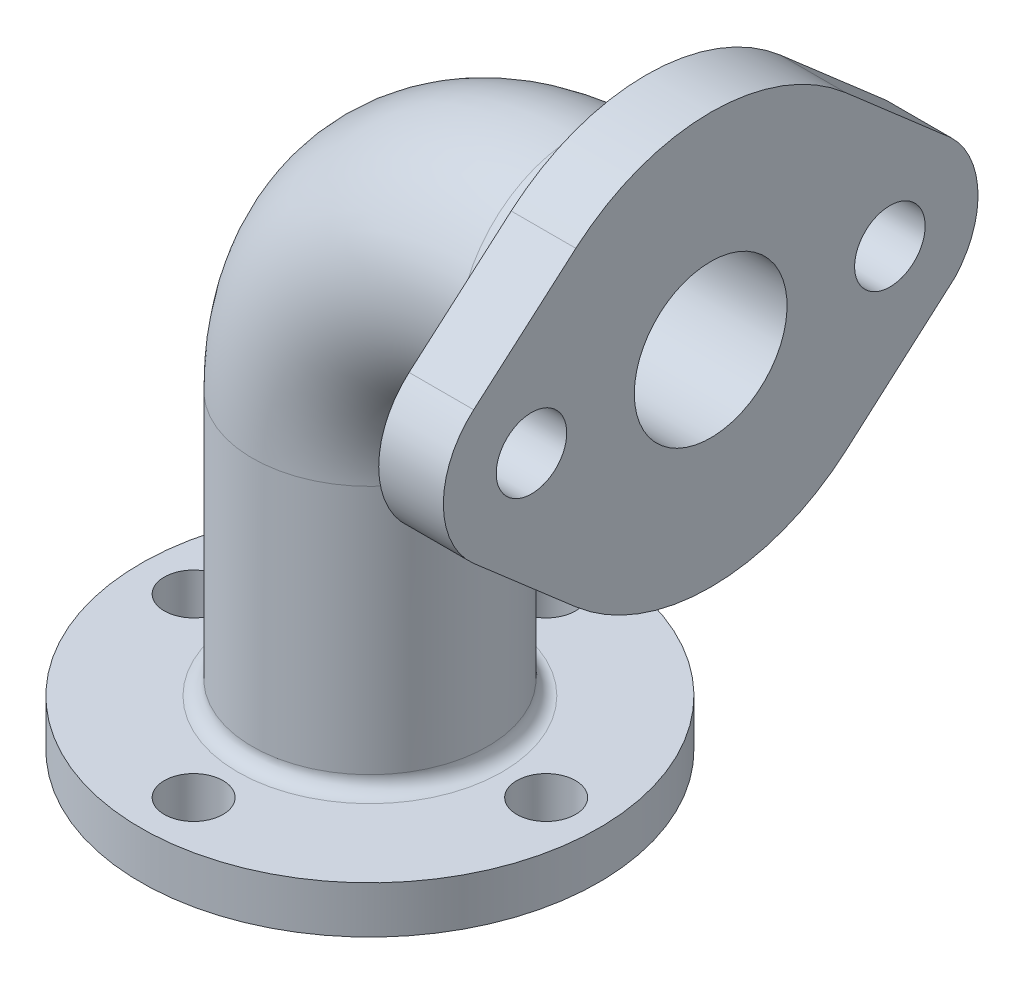
from build123d import *

# Parameters (mm, degrees)
BARRER_L_MINA1_PROFILE_R   = 20
BARRER_L_MINA1_PROFILE_R_2 = 13
CROQUIS166_R               = 6
CROQUIS166_R_2             = 20
SALIENTE_EXTRUIR2_DEPTH    = 11
SALIENTE_EXTRUIR3_START    = -8
CROQUIS167_R               = 39
CROQUIS167_R_2             = 13
SALIENTE_EXTRUIR3_DEPTH    = 8
CROQUIS168_R               = 5
CORTAR_EXTRUIR2_DEPTH      = 15
REDONDEO1_R                = 2.5
REDONDEO2_R                = 2.5


with BuildPart() as part:
    # Barrer-Lámina1: sweep along a path in Croquis8
    with BuildLine(Plane.XY) as barrer_l_mina1_path:
        Line((0, 0), (0, 53))
        ThreePointArc((0, 53), (10.251262658, 77.748737342), (35, 88))
        Line((35, 88), (58, 88))
    # Barrer-Lámina1 profile (on start of the path) → Barrer-Lámina1 (sweep)
    with BuildSketch(Plane.ZX):
        Circle(BARRER_L_MINA1_PROFILE_R)
        Circle(BARRER_L_MINA1_PROFILE_R_2, mode=Mode.SUBTRACT)
    sweep(path=barrer_l_mina1_path.line)

    # Croquis166 → Saliente-Extruir2 (add)
    with BuildSketch(Plane(origin=(58, 0, 0), x_dir=(0, 0, -1), z_dir=(1, 0, 0))):
        with BuildLine():
            Line((-40.336065574, 99.324831744), (-22.950819672, 114.424607403))
            ThreePointArc((-22.950819672, 114.424607403), (0.012124177, 122.9999979), (22.969121399, 114.408700501))
            Line((22.969121399, 114.408700501), (40.855221071, 98.852160917))
            ThreePointArc((40.855221071, 98.852160917), (45.491803378, 88.495813939), (41.549621493, 77.8557472))
            Line((41.549621493, 77.8557472), (23.053076053, 61.664554599))
            ThreePointArc((23.053076053, 61.664554599), (0.067834781, 53.000065737), (-22.950819672, 61.575392597))
            Line((-22.950819672, 61.575392597), (-40.336065574, 76.675168256))
            ThreePointArc((-40.336065574, 76.675168256), (-45.5, 88), (-40.336065574, 99.324831744))
        make_face()
        with Locations((-30.5, 88)):
            Circle(CROQUIS166_R, mode=Mode.SUBTRACT)
        with Locations((30.5, 88)):
            Circle(CROQUIS166_R, mode=Mode.SUBTRACT)
        with Locations((0, 88)):
            Circle(CROQUIS166_R_2, mode=Mode.SUBTRACT)
    extrude(amount=-SALIENTE_EXTRUIR2_DEPTH)

    # Croquis167 → Saliente-Extruir3 (add)
    with BuildSketch(Plane.XZ.offset(SALIENTE_EXTRUIR3_START)):
        Circle(CROQUIS167_R)
        Circle(CROQUIS167_R_2, mode=Mode.SUBTRACT)
    extrude(amount=SALIENTE_EXTRUIR3_DEPTH)

    # Croquis168 → Cortar-Extruir2 (cut)
    with BuildSketch(Plane.XZ):
        with Locations((0, 30)):
            Circle(CROQUIS168_R)
        with Locations((0, -30)):
            Circle(CROQUIS168_R)
        with Locations((30, 0)):
            Circle(CROQUIS168_R)
        with Locations((-30, 0)):
            Circle(CROQUIS168_R)
    extrude(amount=-CORTAR_EXTRUIR2_DEPTH, mode=Mode.SUBTRACT)

    # Redondeo1
    redondeo1_edges = [part.edges().sort_by_distance(p)[0] for p in [
        (47, 88, -20),
    ]]
    fillet(redondeo1_edges, radius=REDONDEO1_R)

    # Redondeo2
    redondeo2_edges = [part.edges().sort_by_distance(p)[0] for p in [
        (0, 8, -20),
    ]]
    fillet(redondeo2_edges, radius=REDONDEO2_R)


solid = part.part
